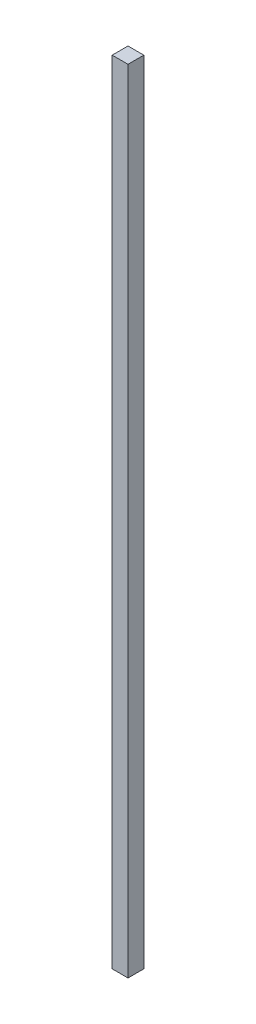
from build123d import *

# Parameters (mm, degrees)
SKETCH1_W           = 25.4
SKETCH1_H           = 25.4
BOSS_EXTRUDE1_DEPTH = 1270


with BuildPart() as part:
    # Sketch1 → Boss-Extrude1 (new body)
    with BuildSketch(Plane(origin=(0, 0, 0), x_dir=(1, 0, 0), z_dir=(0, 1, 0))):
        with Locations((-27.135508984, 5.913615805)):
            Rectangle(SKETCH1_W, SKETCH1_H)
    extrude(amount=BOSS_EXTRUDE1_DEPTH)


solid = part.part
